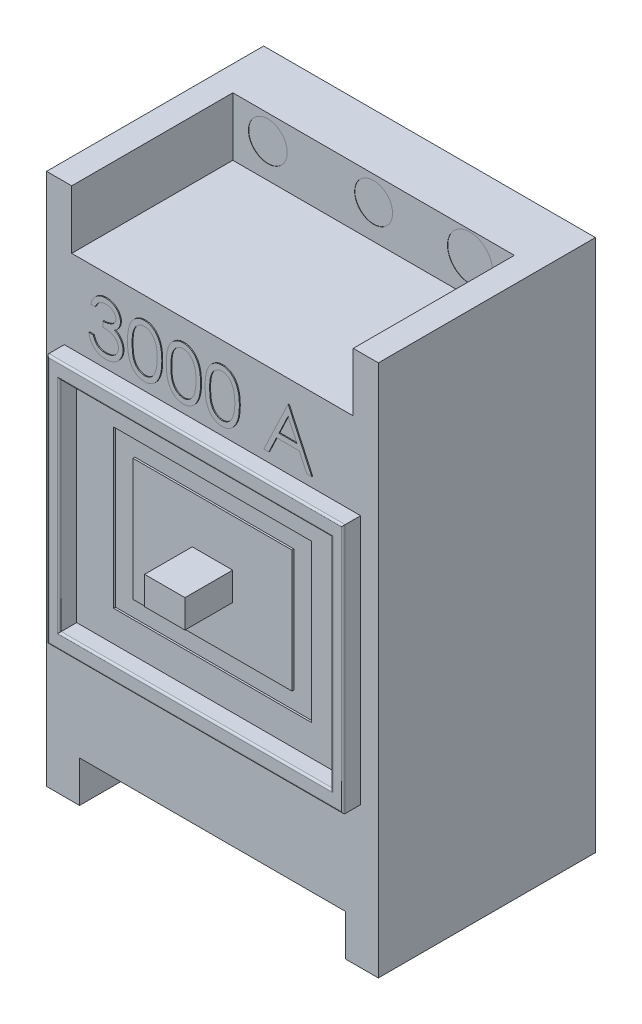
from build123d import *

# Parameters (mm, degrees)
CROQUIS1_W              = 350
CROQUIS1_H              = 562
SALIENTE_EXTRUIR1_DEPTH = 229
CROQUIS2_W              = 208.674633314
CROQUIS2_H              = 165.712208808
CROQUIS2_W_2            = 167.758038546
CROQUIS2_H_2            = 128.887273516
CORTAR_EXTRUIR1_DEPTH   = 2
CROQUIS3_W              = 296.993565644
CROQUIS3_H              = 123.360485072
CROQUIS3_W_2            = 280.429302812
CROQUIS3_H_2            = 86.946646854
CORTAR_EXTRUIR2_DEPTH   = 170
CROQUIS4_R              = 20.028661691
CROQUIS4_R_2            = 20.45866054
CROQUIS4_R_3            = 23.776281168
CORTAR_EXTRUIR4_DEPTH   = 0.3
CROQUIS5_W              = 312.557321138
CROQUIS5_H              = 264.016222022
CROQUIS5_W_2            = 286.51087771
CROQUIS5_H_2            = 230.866203114
SALIENTE_EXTRUIR2_DEPTH = 18.3
REDONDEO2_R             = 2
CROQUIS6_W              = 42.621452882
CROQUIS6_H              = 29.598231168
SALIENTE_EXTRUIR3_DEPTH = 50.3
SALIENTE_EXTRUIR4_DEPTH = 1


with BuildPart() as part:
    # Croquis1 → Saliente-Extruir1 (new body)
    with BuildSketch(Plane.XY):
        Rectangle(CROQUIS1_W, CROQUIS1_H)
    extrude(amount=SALIENTE_EXTRUIR1_DEPTH)

    # Croquis2 → Cortar-Extruir1 (cut)
    with BuildSketch(Plane.XY.offset(229)):
        Rectangle(CROQUIS2_W, CROQUIS2_H)
        Rectangle(CROQUIS2_W_2, CROQUIS2_H_2, mode=Mode.SUBTRACT)
    extrude(amount=-CORTAR_EXTRUIR1_DEPTH, mode=Mode.SUBTRACT)

    # Croquis3 → Cortar-Extruir2 (cut)
    with BuildSketch(Plane.XY.offset(229)):
        with Locations((0, 281)):
            Rectangle(CROQUIS3_W, CROQUIS3_H)
        with Locations((0, -281)):
            Rectangle(CROQUIS3_W_2, CROQUIS3_H_2)
    extrude(amount=-CORTAR_EXTRUIR2_DEPTH, mode=Mode.SUBTRACT)

    # Croquis4 → Cortar-Extruir4 (cut)
    with BuildSketch(Plane.XY.offset(59)):
        with Locations((0, 255.134947076)):
            Circle(CROQUIS4_R)
        with Locations((-111.577875374, 255.134947076)):
            Circle(CROQUIS4_R_2)
        with Locations((101.715058762, 255.134947076)):
            Circle(CROQUIS4_R_3)
        with Locations((101.715058762, -255.134947076)):
            Circle(CROQUIS4_R_3)
        with Locations((-111.577875374, -255.134947076)):
            Circle(CROQUIS4_R_2)
        with Locations((0, -255.134947076)):
            Circle(CROQUIS4_R)
    extrude(amount=-CORTAR_EXTRUIR4_DEPTH, mode=Mode.SUBTRACT)

    # Croquis5 → Saliente-Extruir2 (add)
    with BuildSketch(Plane.XY.offset(229)):
        Rectangle(CROQUIS5_W, CROQUIS5_H)
        Rectangle(CROQUIS5_W_2, CROQUIS5_H_2, mode=Mode.SUBTRACT)
    extrude(amount=SALIENTE_EXTRUIR2_DEPTH)

    # Redondeo2
    redondeo2_edges = [part.edges().sort_by_distance(p)[0] for p in [
        (156.278660569, 0, 247.3),
        (0, 132.008111011, 247.3),
        (-156.278660569, 0, 247.3),
        (0, -132.008111011, 247.3),
        (143.255438855, 0, 247.3),
        (0, 115.433101557, 247.3),
        (-143.255438855, 0, 247.3),
        (0, -115.433101557, 247.3),
    ]]
    fillet(redondeo2_edges, radius=REDONDEO2_R)

    # Croquis6 → Saliente-Extruir3 (add)
    with BuildSketch(Plane.XY.offset(229)):
        Rectangle(CROQUIS6_W, CROQUIS6_H)
    extrude(amount=SALIENTE_EXTRUIR3_DEPTH)

    # Croquis7 → Saliente-Extruir4 (add)
    with BuildSketch(Plane.XY.offset(229)):
        with BuildLine():
            Line((-122.688926728, 183.752225493), (-127.46160301, 183.752225493))
            add(Edge.make_bspline(
                [(-127.46160301, 183.752225493), (-127.332303426, 184.287570504), (-127.079533316, 185.334126213), (-126.55231608, 186.829389396), (-125.977969897, 188.244368045), (-125.288298663, 189.552567136), (-124.536030824, 190.780277606), (-123.674149329, 191.899653642), (-122.742418044, 192.939164219), (-121.711842163, 193.861680181), (-120.631067552, 194.697047141), (-119.484865446, 195.409296896), (-118.296296514, 196.022007998), (-117.057125785, 196.526777557), (-115.763664008, 196.907031451), (-114.427604785, 197.182917627), (-113.045446888, 197.362079397), (-112.107214301, 197.379564831), (-111.630806235, 197.388443442)],
                knots=[0, 0, 0, 0, 0.001651123, 0.003227811, 0.004751232, 0.006228357, 0.007659115, 0.00906539, 0.010460646, 0.011840855, 0.013208797, 0.014553731, 0.015883047, 0.017216413, 0.018561304, 0.019921468, 0.021306273, 0.022734808, 0.022734808, 0.022734808, 0.022734808], degree=3))
            add(Edge.make_bspline(
                [(-111.630806235, 197.388443442), (-110.936673284, 197.367486531), (-109.563548438, 197.32602984), (-107.546261355, 196.947463875), (-105.600939562, 196.34841307), (-103.748875974, 195.520704241), (-102.028562325, 194.499817013), (-100.497911945, 193.284781394), (-99.177672055, 191.89904058), (-98.07006802, 190.368445241), (-97.202833793, 188.732658224), (-96.563346379, 187.049089408), (-96.174034087, 185.321732453), (-96.123579412, 184.155433009), (-96.098301728, 183.571119473)],
                knots=[0, 0, 0, 0, 0.002080695, 0.004116004, 0.006134431, 0.008175559, 0.010187115, 0.012120416, 0.014019275, 0.015911607, 0.017770294, 0.019557065, 0.021301898, 0.023053709, 0.023053709, 0.023053709, 0.023053709], degree=3))
            add(Edge.make_bspline(
                [(-96.098301728, 183.571119473), (-96.115982078, 183.008814444), (-96.15057978, 181.908470762), (-96.444348531, 180.302070371), (-96.938725426, 178.788051841), (-97.623544372, 177.360041647), (-98.510023391, 176.027094037), (-99.58386978, 174.786209991), (-100.852662904, 173.631885765), (-101.814163767, 172.970622916), (-102.309172872, 172.630185229)],
                knots=[0, 0, 0, 0, 0.001685949, 0.003299141, 0.004879172, 0.006451571, 0.008035297, 0.009666887, 0.01136384, 0.013164531, 0.013164531, 0.013164531, 0.013164531], degree=3))
            add(Edge.make_bspline(
                [(-102.309172872, 172.630185229), (-101.743449658, 172.357013333), (-100.622588349, 171.815780798), (-99.094758963, 170.754347511), (-97.707824247, 169.528803119), (-96.934360416, 168.572411988), (-96.545740129, 168.091881442)],
                knots=[0, 0, 0, 0, 0.001882049, 0.003728883, 0.005562024, 0.007413154, 0.007413154, 0.007413154, 0.007413154], degree=3))
            add(Edge.make_bspline(
                [(-96.545740129, 168.091881442), (-96.289841947, 167.741527142), (-95.782236092, 167.046555834), (-95.155676884, 165.929196106), (-94.587258752, 164.799451781), (-94.14433158, 163.627042163), (-93.801329736, 162.42555596), (-93.556148489, 161.192930124), (-93.403835248, 159.928158101), (-93.382022548, 159.072510076), (-93.371058138, 158.642408536)],
                knots=[0, 0, 0, 0, 0.0013004, 0.002579506, 0.003837317, 0.005091694, 0.006332609, 0.007582, 0.008858485, 0.010148634, 0.010148634, 0.010148634, 0.010148634], degree=3))
            add(Edge.make_bspline(
                [(-93.371058138, 158.642408536), (-93.39832513, 157.897723326), (-93.452730795, 156.411857406), (-93.939021274, 154.216615609), (-94.692876748, 152.07074454), (-95.763444726, 150.018330599), (-97.068170856, 148.098025845), (-98.620414912, 146.379871714), (-100.40254, 144.902973635), (-102.390085118, 143.669013223), (-104.543426272, 142.68260858), (-106.846563258, 141.997976828), (-109.266310953, 141.552074844), (-110.925676837, 141.504259295), (-111.769299073, 141.479949852)],
                knots=[0, 0, 0, 0, 0.002231528, 0.004452555, 0.00671349, 0.009038643, 0.011375992, 0.013661291, 0.015961021, 0.018296305, 0.020660953, 0.023043603, 0.025488667, 0.028017294, 0.028017294, 0.028017294, 0.028017294], degree=3))
            add(Edge.make_bspline(
                [(-111.769299073, 141.479949852), (-112.337871977, 141.493142042), (-113.456633855, 141.519099874), (-115.101355154, 141.696552048), (-116.671291476, 142.02065386), (-118.168565472, 142.456790334), (-119.594507284, 143.009749858), (-120.944765625, 143.698351289), (-122.227647704, 144.508400523), (-123.431047481, 145.44945927), (-124.554821504, 146.502164484), (-125.569105308, 147.685204334), (-126.490809198, 148.976709531), (-127.295253685, 150.391681111), (-128.019080166, 151.911833065), (-128.61442081, 153.556630338), (-129.138416709, 155.311368808), (-129.382039472, 156.534199328), (-129.507035702, 157.161600493)],
                knots=[0, 0, 0, 0, 0.001705725, 0.003356299, 0.004954612, 0.006508716, 0.00803005, 0.009535598, 0.011048816, 0.01257462, 0.01411202, 0.015660417, 0.017241884, 0.018864546, 0.020537249, 0.022286629, 0.024107065, 0.02602525, 0.02602525, 0.02602525, 0.02602525], degree=3))
            Line((-129.507035702, 157.161600493), (-124.73435942, 157.161600493))
            add(Edge.make_bspline(
                [(-124.73435942, 157.161600493), (-124.610017229, 156.752119861), (-124.368160868, 155.955644464), (-123.956472685, 154.809355962), (-123.487440316, 153.758524043), (-122.984276424, 152.795440141), (-122.455830357, 151.910619583), (-121.864531968, 151.127459291), (-121.254176154, 150.41156062), (-120.794092194, 150.008224722), (-120.568920969, 149.810826755)],
                knots=[0, 0, 0, 0, 0.001283755, 0.002497015, 0.003651166, 0.00473283, 0.00575599, 0.006738233, 0.007674269, 0.008571489, 0.008571489, 0.008571489, 0.008571489], degree=3))
            add(Edge.make_bspline(
                [(-120.568920969, 149.810826755), (-120.271157987, 149.581261017), (-119.67655115, 149.122838159), (-118.707615653, 148.537819664), (-117.688588661, 148.030910799), (-116.597390334, 147.643695144), (-115.457567688, 147.315830295), (-114.25069724, 147.101274049), (-112.987426529, 146.954065746), (-112.124860637, 146.941075367), (-111.684072711, 146.934437031)],
                knots=[0, 0, 0, 0, 0.001127137, 0.002250794, 0.003389502, 0.004535412, 0.005719271, 0.006943705, 0.008208399, 0.009530095, 0.009530095, 0.009530095, 0.009530095], degree=3))
            add(Edge.make_bspline(
                [(-111.684072711, 146.934437031), (-111.186394936, 146.943795492), (-110.21322901, 146.962095153), (-108.793215799, 147.130386563), (-107.442298886, 147.375482434), (-106.175477055, 147.754026311), (-104.976156185, 148.221730355), (-103.861148227, 148.808979073), (-102.815815964, 149.497975924), (-101.853548266, 150.281095032), (-100.988281617, 151.1383995), (-100.22642962, 152.035082039), (-99.578763112, 152.967361956), (-99.056316921, 153.940398332), (-98.643774006, 154.950161801), (-98.362928375, 155.999486049), (-98.167654192, 157.079783617), (-98.151751294, 157.81412504), (-98.14373442, 158.184316839)],
                knots=[0, 0, 0, 0, 0.001492412, 0.002918283, 0.004284732, 0.00560617, 0.006878202, 0.008140966, 0.009378996, 0.010628524, 0.011856429, 0.013028146, 0.014154023, 0.015255081, 0.016335223, 0.017418145, 0.018509262, 0.019618485, 0.019618485, 0.019618485, 0.019618485], degree=3))
            add(Edge.make_bspline(
                [(-98.14373442, 158.184316839), (-98.166986805, 158.679834486), (-98.213375875, 159.668404154), (-98.567541415, 161.12279851), (-99.150086764, 162.524100325), (-99.965621405, 163.848401428), (-100.958374467, 165.075762403), (-102.118711954, 166.17086284), (-103.456269445, 167.074489634), (-104.68733742, 167.698817094), (-105.777783342, 168.124830438), (-106.710968175, 168.408589853), (-107.755700207, 168.648872703), (-108.899345498, 168.872420415), (-110.150521263, 169.062677828), (-111.507865364, 169.221337489), (-112.971652856, 169.348289352), (-113.985001303, 169.404982013), (-114.507195958, 169.434196647)],
                knots=[0, 0, 0, 0, 0.001485438, 0.002963484, 0.004463141, 0.00602162, 0.007612211, 0.009187495, 0.010789071, 0.012437546, 0.013317911, 0.014298535, 0.015360557, 0.016532661, 0.017793761, 0.019156134, 0.020631837, 0.022200803, 0.022200803, 0.022200803, 0.022200803], degree=3))
            Line((-114.507195958, 169.434196647), (-114.507195958, 174.888683826))
            add(Edge.make_bspline(
                [(-114.507195958, 174.888683826), (-113.84925021, 174.899848906), (-112.560496116, 174.921718556), (-110.677966403, 175.186227056), (-108.877806737, 175.552123599), (-107.19991183, 176.112580923), (-105.670590577, 176.763523933), (-104.343800409, 177.521010453), (-103.238129594, 178.363017776), (-102.358951278, 179.302542192), (-101.697540194, 180.310175655), (-101.213943374, 181.360378584), (-100.928279131, 182.462355788), (-100.890145639, 183.214409591), (-100.87097801, 183.592426064)],
                knots=[0, 0, 0, 0, 0.00197227, 0.003863192, 0.005693576, 0.007475736, 0.009159968, 0.01067296, 0.012047401, 0.013313755, 0.014513374, 0.015648088, 0.01676947, 0.017902783, 0.017902783, 0.017902783, 0.017902783], degree=3))
            add(Edge.make_bspline(
                [(-100.87097801, 183.592426064), (-100.877274836, 183.870149874), (-100.889802074, 184.422668221), (-101.047784997, 185.229884667), (-101.285186719, 186.012423147), (-101.611563535, 186.766955839), (-102.048412536, 187.488249697), (-102.571199214, 188.182454167), (-103.193694866, 188.845605802), (-103.907014167, 189.463728728), (-104.673003539, 190.052813441), (-105.512504139, 190.5529244), (-106.40020366, 190.980578567), (-107.3370849, 191.333238662), (-108.326188235, 191.598526311), (-109.362866412, 191.789003944), (-110.449096231, 191.908094308), (-111.190165281, 191.925240185), (-111.566886463, 191.933956262)],
                knots=[0, 0, 0, 0, 0.000832049, 0.001655322, 0.002457367, 0.003282705, 0.004114004, 0.004981185, 0.005885649, 0.00683672, 0.007810434, 0.008780586, 0.009762135, 0.010763375, 0.01177902, 0.012830031, 0.013922968, 0.015053021, 0.015053021, 0.015053021, 0.015053021], degree=3))
            add(Edge.make_bspline(
                [(-111.566886463, 191.933956262), (-112.172418326, 191.912815013), (-113.355162889, 191.871521238), (-115.060228475, 191.509842949), (-116.645323498, 190.932779534), (-117.856924059, 190.243960494), (-118.751623744, 189.563993634), (-119.390967792, 188.970150731), (-120.01881819, 188.310204488), (-120.593869734, 187.543507496), (-121.17542914, 186.721981929), (-121.704879808, 185.803865668), (-122.219365739, 184.813108183), (-122.529375194, 184.112701479), (-122.688926728, 183.752225493)],
                knots=[0, 0, 0, 0, 0.001814848, 0.003544819, 0.005203179, 0.006858867, 0.007702632, 0.008569747, 0.009474211, 0.010430993, 0.011441654, 0.012492233, 0.01360717, 0.014789494, 0.014789494, 0.014789494, 0.014789494], degree=3))
        make_face()
        with BuildLine():
            add(Edge.make_bspline(
                [(-88.598381856, 169.412890056), (-88.593397737, 170.265269828), (-88.583716015, 171.921029821), (-88.47600999, 174.333705748), (-88.297087869, 176.597104139), (-88.051886252, 178.711333334), (-87.753494156, 180.676939145), (-87.3551592, 182.488668696), (-86.902164311, 184.154907254), (-86.377152238, 185.681088309), (-85.784746708, 187.087773443), (-85.139973271, 188.40097351), (-84.417243207, 189.61870155), (-83.657861864, 190.760393441), (-82.831089869, 191.807360474), (-81.960455211, 192.774388002), (-81.011977095, 193.63912653), (-80.01789785, 194.426912578), (-78.969217322, 195.117501068), (-77.895827239, 195.725784234), (-76.79033939, 196.245439003), (-75.64973555, 196.654029572), (-74.484267577, 196.991515456), (-73.289861272, 197.222306091), (-72.064544548, 197.367519902), (-71.237478336, 197.381402757), (-70.818032046, 197.388443442)],
                knots=[0, 0, 0, 0, 0.002556991, 0.004966991, 0.007243359, 0.009366895, 0.011351298, 0.013204757, 0.01492865, 0.016528951, 0.018042544, 0.019505191, 0.020913886, 0.02228783, 0.023615566, 0.024912646, 0.026186817, 0.0274613, 0.028714094, 0.0299496, 0.031160192, 0.032373452, 0.03358071, 0.03479668, 0.036019027, 0.037276838, 0.037276838, 0.037276838, 0.037276838], degree=3))
            add(Edge.make_bspline(
                [(-70.818032046, 197.388443442), (-70.395081892, 197.381031264), (-69.553967107, 197.366290776), (-68.310431834, 197.224616799), (-67.095624973, 196.989538609), (-65.914725612, 196.656457229), (-64.75803363, 196.243228635), (-63.634596322, 195.725287064), (-62.537435505, 195.122380846), (-61.483986547, 194.413947682), (-60.462684472, 193.62409556), (-59.498615334, 192.731217794), (-58.591691381, 191.744330006), (-57.730530357, 190.673991042), (-56.939564149, 189.49967178), (-56.186313551, 188.241796797), (-55.512096312, 186.878368353), (-54.862758185, 185.432135137), (-54.302273596, 183.863080722), (-53.79680488, 182.180049745), (-53.388388552, 180.36316268), (-53.048191555, 178.42195216), (-52.784642055, 176.349289169), (-52.592693571, 174.149616708), (-52.491298427, 171.821487593), (-52.472203301, 170.229729489), (-52.462404292, 169.412890056)],
                knots=[0, 0, 0, 0, 0.001268458, 0.002522564, 0.003748989, 0.004976756, 0.00620003, 0.007429967, 0.008684073, 0.009951636, 0.011234507, 0.012553839, 0.013888226, 0.015252513, 0.016670842, 0.018132481, 0.019647535, 0.021231118, 0.022885812, 0.024641926, 0.026500033, 0.028468674, 0.030552503, 0.032766057, 0.035090918, 0.037541546, 0.037541546, 0.037541546, 0.037541546], degree=3))
            add(Edge.make_bspline(
                [(-52.462404292, 169.412890056), (-52.472304886, 168.599613391), (-52.491595791, 167.014976974), (-52.591556891, 164.69732328), (-52.788458663, 162.50932444), (-53.034763646, 160.445732966), (-53.37589801, 158.515137826), (-53.795348653, 156.71085834), (-54.261069361, 155.025102794), (-54.835955545, 153.471681344), (-55.4651765, 152.028923827), (-56.149774114, 150.681658175), (-56.883216883, 149.417976059), (-57.682284081, 148.247992405), (-58.533995676, 147.163419203), (-59.456580791, 146.183400862), (-60.424032593, 145.284323634), (-61.448340175, 144.484300958), (-62.518218549, 143.784058811), (-63.611611023, 143.157829073), (-64.747917825, 142.652870141), (-65.90138803, 142.219290384), (-67.08852065, 141.888040304), (-68.307835897, 141.658998453), (-69.553131632, 141.498362991), (-70.394938627, 141.486108817), (-70.818032046, 141.479949852)],
                knots=[0, 0, 0, 0, 0.002439977, 0.004754195, 0.006957136, 0.009029058, 0.010987208, 0.012834933, 0.014585091, 0.016229775, 0.01779932, 0.019304869, 0.020761101, 0.02217943, 0.023552053, 0.024893691, 0.026213023, 0.027510847, 0.028787287, 0.030046586, 0.03128622, 0.032513154, 0.03374092, 0.034977804, 0.036233131, 0.037501589, 0.037501589, 0.037501589, 0.037501589], degree=3))
            add(Edge.make_bspline(
                [(-70.818032046, 141.479949852), (-71.2374667, 141.487035957), (-72.064509967, 141.501008372), (-73.289994767, 141.645566124), (-74.479468537, 141.877975833), (-75.638800855, 142.203393483), (-76.773939671, 142.601718558), (-77.869416998, 143.120671583), (-78.937413249, 143.718338713), (-79.975079053, 144.398989143), (-80.962915621, 145.178803789), (-81.906481751, 146.041316883), (-82.782073336, 147.008051895), (-83.597024264, 148.063744123), (-84.371557329, 149.198681264), (-85.08402461, 150.428358989), (-85.743029248, 151.747901441), (-86.345397931, 153.165833766), (-86.87946932, 154.702846768), (-87.351228156, 156.376524196), (-87.723712024, 158.201638388), (-88.042540536, 160.163530668), (-88.299700492, 162.270631514), (-88.475264339, 164.524084847), (-88.58377407, 166.922486423), (-88.593423738, 168.567606976), (-88.598381856, 169.412890056)],
                knots=[0, 0, 0, 0, 0.001257811, 0.002480158, 0.003696128, 0.004890247, 0.006089867, 0.007300458, 0.008521458, 0.009759488, 0.011019012, 0.012293184, 0.013590264, 0.014926392, 0.016291511, 0.017709401, 0.019186333, 0.020713883, 0.022327743, 0.024064753, 0.0259264, 0.027912489, 0.030026705, 0.032292454, 0.034691811, 0.037227497, 0.037227497, 0.037227497, 0.037227497], degree=3))
        make_face()
        with BuildLine():
            add(Edge.make_bspline(
                [(-83.825705574, 169.434196647), (-83.823890618, 168.723866864), (-83.820368146, 167.345256237), (-83.728346341, 165.341944974), (-83.602987012, 163.473454745), (-83.441296302, 161.737413063), (-83.201176143, 160.139696177), (-82.932127826, 158.669315403), (-82.6047123, 157.33405217), (-82.217324609, 156.124743811), (-81.776085903, 155.020867161), (-81.294326628, 153.99369084), (-80.776786108, 153.031080792), (-80.197579229, 152.141683518), (-79.56677267, 151.322598607), (-78.898614702, 150.55932866), (-78.168168954, 149.878654527), (-77.157668337, 149.062294153), (-75.823632264, 148.218700745), (-74.142793954, 147.484099176), (-72.415642437, 147.022448602), (-71.243356746, 146.96374021), (-70.658232617, 146.934437031)],
                knots=[0, 0, 0, 0, 0.002130766, 0.004135398, 0.006014731, 0.007748962, 0.009364052, 0.010860072, 0.012232074, 0.013485365, 0.014666392, 0.015795893, 0.016887583, 0.017942474, 0.018975899, 0.01998712, 0.020981935, 0.02196689, 0.023882114, 0.025695053, 0.027454654, 0.029208149, 0.029208149, 0.029208149, 0.029208149], degree=3))
            add(Edge.make_bspline(
                [(-70.658232617, 146.934437031), (-70.069323638, 146.95871474), (-68.892721558, 147.007220033), (-67.173693946, 147.475195848), (-65.504862217, 148.181283904), (-64.197029824, 149.016191625), (-63.202045963, 149.811301902), (-62.489159054, 150.489205549), (-61.834846607, 151.248267112), (-61.214265866, 152.067247664), (-60.64508859, 152.961794035), (-60.127511378, 153.927604665), (-59.655211013, 154.967361584), (-59.386128384, 155.69320571), (-59.24855338, 156.06431108)],
                knots=[0, 0, 0, 0, 0.001763241, 0.003522842, 0.005307769, 0.007184595, 0.008154571, 0.009126593, 0.010130776, 0.011157756, 0.012206875, 0.013307933, 0.014442647, 0.015629713, 0.015629713, 0.015629713, 0.015629713], degree=3))
            add(Edge.make_bspline(
                [(-59.24855338, 156.06431108), (-59.088223037, 156.538835818), (-58.762683682, 157.502324539), (-58.343132633, 158.996925102), (-58.012719058, 160.565054242), (-57.715460703, 162.197340525), (-57.512565787, 163.905821625), (-57.349256603, 165.685211304), (-57.253064076, 167.536851182), (-57.241140064, 168.794891503), (-57.235080574, 169.434196647)],
                knots=[0, 0, 0, 0, 0.00150253, 0.003050781, 0.004653491, 0.00630863, 0.008026423, 0.009812685, 0.011668836, 0.013586696, 0.013586696, 0.013586696, 0.013586696], degree=3))
            add(Edge.make_bspline(
                [(-57.235080574, 169.434196647), (-57.243440503, 170.073398387), (-57.259794311, 171.323813635), (-57.322304885, 173.155044348), (-57.483726305, 174.894341094), (-57.663009702, 176.54919683), (-57.927354263, 178.110450983), (-58.21237244, 179.591173567), (-58.59529586, 180.97302035), (-59.004332226, 182.27762603), (-59.472485183, 183.490168475), (-59.987822652, 184.616300989), (-60.53819934, 185.661460316), (-61.135990633, 186.622778898), (-61.774100039, 187.504562662), (-62.469369657, 188.289131885), (-63.194220565, 189.000802888), (-64.20948384, 189.813147532), (-65.538624433, 190.641433276), (-67.192495171, 191.403684081), (-68.913602156, 191.841415799), (-70.077108443, 191.903131683), (-70.658232617, 191.933956262)],
                knots=[0, 0, 0, 0, 0.001917859, 0.003751743, 0.005494624, 0.007156981, 0.00874375, 0.010243861, 0.011678105, 0.013042601, 0.014344397, 0.015574333, 0.016756225, 0.017885474, 0.018967925, 0.020017207, 0.021026743, 0.022011698, 0.023912229, 0.025709987, 0.02745664, 0.02919952, 0.02919952, 0.02919952, 0.02919952], degree=3))
            add(Edge.make_bspline(
                [(-70.658232617, 191.933956262), (-71.246426239, 191.903089156), (-72.42388503, 191.841298711), (-74.162880828, 191.40531497), (-75.829799271, 190.645385814), (-77.155425113, 189.810404141), (-78.171396469, 189.015142191), (-78.886801179, 188.325511231), (-79.5575865, 187.571154126), (-80.175517679, 186.744536459), (-80.754270734, 185.856176084), (-81.285794727, 184.899084299), (-81.764689295, 183.868410946), (-82.206618435, 182.765030144), (-82.595187816, 181.555826115), (-82.915703054, 180.222207603), (-83.211801866, 178.756503608), (-83.42141605, 177.150133442), (-83.607759439, 175.413656937), (-83.727513706, 173.540502114), (-83.820675974, 171.533831019), (-83.823995462, 170.148092377), (-83.825705574, 169.434196647)],
                knots=[0, 0, 0, 0, 0.00176411, 0.003531433, 0.005338918, 0.007239449, 0.008217756, 0.00920484, 0.010216062, 0.011243041, 0.012297933, 0.013394757, 0.014524257, 0.015705284, 0.016958576, 0.018330578, 0.019818153, 0.021442283, 0.023188189, 0.025056893, 0.027072169, 0.029213587, 0.029213587, 0.029213587, 0.029213587], degree=3))
        make_face(mode=Mode.SUBTRACT)
        with BuildLine():
            add(Edge.make_bspline(
                [(-47.68972801, 169.412890056), (-47.684743891, 170.265269828), (-47.675062169, 171.921029821), (-47.567356144, 174.333705748), (-47.388434023, 176.597104139), (-47.143232406, 178.711333334), (-46.84484031, 180.676939145), (-46.446505354, 182.488668696), (-45.993510465, 184.154907254), (-45.468498391, 185.681088309), (-44.876092861, 187.087773443), (-44.231319425, 188.40097351), (-43.508589361, 189.61870155), (-42.749208018, 190.760393441), (-41.922436023, 191.807360474), (-41.051801365, 192.774388002), (-40.103323249, 193.63912653), (-39.109244004, 194.426912578), (-38.060563476, 195.117501068), (-36.987173393, 195.725784234), (-35.881685544, 196.245439003), (-34.741081704, 196.654029572), (-33.575613731, 196.991515456), (-32.381207426, 197.222306091), (-31.155890702, 197.367519902), (-30.32882449, 197.381402757), (-29.9093782, 197.388443442)],
                knots=[0, 0, 0, 0, 0.002556991, 0.004966991, 0.007243359, 0.009366895, 0.011351298, 0.013204757, 0.01492865, 0.016528951, 0.018042544, 0.019505191, 0.020913886, 0.02228783, 0.023615566, 0.024912646, 0.026186817, 0.0274613, 0.028714094, 0.0299496, 0.031160192, 0.032373452, 0.03358071, 0.03479668, 0.036019027, 0.037276838, 0.037276838, 0.037276838, 0.037276838], degree=3))
            add(Edge.make_bspline(
                [(-29.9093782, 197.388443442), (-29.486428046, 197.381031264), (-28.645313261, 197.366290776), (-27.401777987, 197.224616799), (-26.186971127, 196.989538609), (-25.006071766, 196.656457229), (-23.849379784, 196.243228635), (-22.725942476, 195.725287064), (-21.628781659, 195.122380846), (-20.575332701, 194.413947682), (-19.554030626, 193.62409556), (-18.589961488, 192.731217794), (-17.683037535, 191.744330006), (-16.821876511, 190.673991042), (-16.030910303, 189.49967178), (-15.277659704, 188.241796797), (-14.603442466, 186.878368353), (-13.954104339, 185.432135137), (-13.39361975, 183.863080722), (-12.888151033, 182.180049745), (-12.479734706, 180.36316268), (-12.139537709, 178.42195216), (-11.875988209, 176.349289169), (-11.684039725, 174.149616708), (-11.582644581, 171.821487593), (-11.563549455, 170.229729489), (-11.553750446, 169.412890056)],
                knots=[0, 0, 0, 0, 0.001268458, 0.002522564, 0.003748989, 0.004976756, 0.00620003, 0.007429967, 0.008684073, 0.009951636, 0.011234507, 0.012553839, 0.013888226, 0.015252513, 0.016670842, 0.018132481, 0.019647535, 0.021231118, 0.022885812, 0.024641926, 0.026500033, 0.028468674, 0.030552503, 0.032766057, 0.035090918, 0.037541546, 0.037541546, 0.037541546, 0.037541546], degree=3))
            add(Edge.make_bspline(
                [(-11.553750446, 169.412890056), (-11.56365104, 168.599613391), (-11.582941945, 167.014976974), (-11.682903044, 164.69732328), (-11.879804817, 162.50932444), (-12.1261098, 160.445732966), (-12.467244164, 158.515137826), (-12.886694807, 156.71085834), (-13.352415515, 155.025102794), (-13.927301699, 153.471681344), (-14.556522654, 152.028923827), (-15.241120268, 150.681658175), (-15.974563036, 149.417976059), (-16.773630235, 148.247992405), (-17.625341829, 147.163419203), (-18.547926945, 146.183400862), (-19.515378746, 145.284323634), (-20.539686329, 144.484300958), (-21.609564703, 143.784058811), (-22.702957177, 143.157829073), (-23.839263979, 142.652870141), (-24.992734184, 142.219290384), (-26.179866804, 141.888040304), (-27.399182051, 141.658998453), (-28.644477786, 141.498362991), (-29.486284781, 141.486108817), (-29.9093782, 141.479949852)],
                knots=[0, 0, 0, 0, 0.002439977, 0.004754195, 0.006957136, 0.009029058, 0.010987208, 0.012834933, 0.014585091, 0.016229775, 0.01779932, 0.019304869, 0.020761101, 0.02217943, 0.023552053, 0.024893691, 0.026213023, 0.027510847, 0.028787287, 0.030046586, 0.03128622, 0.032513154, 0.03374092, 0.034977804, 0.036233131, 0.037501589, 0.037501589, 0.037501589, 0.037501589], degree=3))
            add(Edge.make_bspline(
                [(-29.9093782, 141.479949852), (-30.328812853, 141.487035957), (-31.155856121, 141.501008372), (-32.381340921, 141.645566124), (-33.570814691, 141.877975833), (-34.730147009, 142.203393483), (-35.865285825, 142.601718558), (-36.960763152, 143.120671583), (-38.028759403, 143.718338713), (-39.066425207, 144.398989143), (-40.054261775, 145.178803789), (-40.997827905, 146.041316883), (-41.87341949, 147.008051895), (-42.688370418, 148.063744123), (-43.462903483, 149.198681264), (-44.175370764, 150.428358989), (-44.834375402, 151.747901441), (-45.436744084, 153.165833766), (-45.970815473, 154.702846768), (-46.44257431, 156.376524196), (-46.815058177, 158.201638388), (-47.13388669, 160.163530668), (-47.391046646, 162.270631514), (-47.566610492, 164.524084847), (-47.675120224, 166.922486423), (-47.684769892, 168.567606976), (-47.68972801, 169.412890056)],
                knots=[0, 0, 0, 0, 0.001257811, 0.002480158, 0.003696128, 0.004890247, 0.006089867, 0.007300458, 0.008521458, 0.009759488, 0.011019012, 0.012293184, 0.013590264, 0.014926392, 0.016291511, 0.017709401, 0.019186333, 0.020713883, 0.022327743, 0.024064753, 0.0259264, 0.027912489, 0.030026705, 0.032292454, 0.034691811, 0.037227497, 0.037227497, 0.037227497, 0.037227497], degree=3))
        make_face()
        with BuildLine():
            add(Edge.make_bspline(
                [(-42.917051728, 169.434196647), (-42.915236772, 168.723866864), (-42.9117143, 167.345256237), (-42.819692495, 165.341944974), (-42.694333166, 163.473454745), (-42.532642456, 161.737413063), (-42.292522297, 160.139696177), (-42.02347398, 158.669315403), (-41.696058454, 157.33405217), (-41.308670763, 156.124743811), (-40.867432057, 155.020867161), (-40.385672782, 153.99369084), (-39.868132262, 153.031080792), (-39.288925383, 152.141683518), (-38.658118824, 151.322598607), (-37.989960856, 150.55932866), (-37.259515108, 149.878654527), (-36.249014491, 149.062294153), (-34.914978418, 148.218700745), (-33.234140108, 147.484099176), (-31.506988591, 147.022448602), (-30.3347029, 146.96374021), (-29.749578771, 146.934437031)],
                knots=[0, 0, 0, 0, 0.002130766, 0.004135398, 0.006014731, 0.007748962, 0.009364052, 0.010860072, 0.012232074, 0.013485365, 0.014666392, 0.015795893, 0.016887583, 0.017942474, 0.018975899, 0.01998712, 0.020981935, 0.02196689, 0.023882114, 0.025695053, 0.027454654, 0.029208149, 0.029208149, 0.029208149, 0.029208149], degree=3))
            add(Edge.make_bspline(
                [(-29.749578771, 146.934437031), (-29.160669792, 146.95871474), (-27.984067712, 147.007220033), (-26.2650401, 147.475195848), (-24.596208371, 148.181283904), (-23.288375978, 149.016191625), (-22.293392116, 149.811301902), (-21.580505208, 150.489205549), (-20.926192761, 151.248267112), (-20.30561202, 152.067247664), (-19.736434744, 152.961794035), (-19.218857532, 153.927604665), (-18.746557167, 154.967361584), (-18.477474538, 155.69320571), (-18.339899534, 156.06431108)],
                knots=[0, 0, 0, 0, 0.001763241, 0.003522842, 0.005307769, 0.007184595, 0.008154571, 0.009126593, 0.010130776, 0.011157756, 0.012206875, 0.013307933, 0.014442647, 0.015629713, 0.015629713, 0.015629713, 0.015629713], degree=3))
            add(Edge.make_bspline(
                [(-18.339899534, 156.06431108), (-18.179569191, 156.538835818), (-17.854029836, 157.502324539), (-17.434478787, 158.996925102), (-17.104065212, 160.565054242), (-16.806806857, 162.197340525), (-16.603911941, 163.905821625), (-16.440602757, 165.685211304), (-16.34441023, 167.536851182), (-16.332486217, 168.794891503), (-16.326426728, 169.434196647)],
                knots=[0, 0, 0, 0, 0.00150253, 0.003050781, 0.004653491, 0.00630863, 0.008026423, 0.009812685, 0.011668836, 0.013586696, 0.013586696, 0.013586696, 0.013586696], degree=3))
            add(Edge.make_bspline(
                [(-16.326426728, 169.434196647), (-16.334786657, 170.073398387), (-16.351140465, 171.323813635), (-16.413651039, 173.155044348), (-16.575072459, 174.894341094), (-16.754355856, 176.54919683), (-17.018700417, 178.110450983), (-17.303718593, 179.591173567), (-17.686642014, 180.97302035), (-18.09567838, 182.27762603), (-18.563831337, 183.490168475), (-19.079168806, 184.616300989), (-19.629545494, 185.661460316), (-20.227336787, 186.622778898), (-20.865446193, 187.504562662), (-21.560715811, 188.289131885), (-22.285566719, 189.000802888), (-23.300829994, 189.813147532), (-24.629970587, 190.641433276), (-26.283841324, 191.403684081), (-28.00494831, 191.841415799), (-29.168454597, 191.903131683), (-29.749578771, 191.933956262)],
                knots=[0, 0, 0, 0, 0.001917859, 0.003751743, 0.005494624, 0.007156981, 0.00874375, 0.010243861, 0.011678105, 0.013042601, 0.014344397, 0.015574333, 0.016756225, 0.017885474, 0.018967925, 0.020017207, 0.021026743, 0.022011698, 0.023912229, 0.025709987, 0.02745664, 0.02919952, 0.02919952, 0.02919952, 0.02919952], degree=3))
            add(Edge.make_bspline(
                [(-29.749578771, 191.933956262), (-30.337772393, 191.903089156), (-31.515231184, 191.841298711), (-33.254226981, 191.40531497), (-34.921145424, 190.645385814), (-36.246771267, 189.810404141), (-37.262742623, 189.015142191), (-37.978147333, 188.325511231), (-38.648932654, 187.571154126), (-39.266863833, 186.744536459), (-39.845616888, 185.856176084), (-40.377140881, 184.899084299), (-40.856035449, 183.868410946), (-41.297964589, 182.765030144), (-41.68653397, 181.555826115), (-42.007049207, 180.222207603), (-42.30314802, 178.756503608), (-42.512762204, 177.150133442), (-42.699105593, 175.413656937), (-42.81885986, 173.540502114), (-42.912022128, 171.533831019), (-42.915341616, 170.148092377), (-42.917051728, 169.434196647)],
                knots=[0, 0, 0, 0, 0.00176411, 0.003531433, 0.005338918, 0.007239449, 0.008217756, 0.00920484, 0.010216062, 0.011243041, 0.012297933, 0.013394757, 0.014524257, 0.015705284, 0.016958576, 0.018330578, 0.019818153, 0.021442283, 0.023188189, 0.025056893, 0.027072169, 0.029213587, 0.029213587, 0.029213587, 0.029213587], degree=3))
        make_face(mode=Mode.SUBTRACT)
        with BuildLine():
            add(Edge.make_bspline(
                [(-6.781074164, 169.412890056), (-6.776090045, 170.265269828), (-6.766408322, 171.921029821), (-6.658702298, 174.333705748), (-6.479780177, 176.597104139), (-6.23457856, 178.711333334), (-5.936186464, 180.676939145), (-5.537851507, 182.488668696), (-5.084856619, 184.154907254), (-4.559844545, 185.681088309), (-3.967439015, 187.087773443), (-3.322665579, 188.40097351), (-2.599935515, 189.61870155), (-1.840554172, 190.760393441), (-1.013782176, 191.807360474), (-0.143147519, 192.774388002), (0.805330597, 193.63912653), (1.799409843, 194.426912578), (2.84809037, 195.117501068), (3.921480453, 195.725784234), (5.026968302, 196.245439003), (6.167572142, 196.654029572), (7.333040116, 196.991515456), (8.52744642, 197.222306091), (9.752763144, 197.367519902), (10.579829356, 197.381402757), (10.999275646, 197.388443442)],
                knots=[0, 0, 0, 0, 0.002556991, 0.004966991, 0.007243359, 0.009366895, 0.011351298, 0.013204757, 0.01492865, 0.016528951, 0.018042544, 0.019505191, 0.020913886, 0.02228783, 0.023615566, 0.024912646, 0.026186817, 0.0274613, 0.028714094, 0.0299496, 0.031160192, 0.032373452, 0.03358071, 0.03479668, 0.036019027, 0.037276838, 0.037276838, 0.037276838, 0.037276838], degree=3))
            add(Edge.make_bspline(
                [(10.999275646, 197.388443442), (11.4222258, 197.381031264), (12.263340586, 197.366290776), (13.506875859, 197.224616799), (14.721682719, 196.989538609), (15.90258208, 196.656457229), (17.059274062, 196.243228635), (18.18271137, 195.725287064), (19.279872188, 195.122380846), (20.333321146, 194.413947682), (21.354623221, 193.62409556), (22.318692358, 192.731217794), (23.225616311, 191.744330006), (24.086777335, 190.673991042), (24.877743544, 189.49967178), (25.630994142, 188.241796797), (26.30521138, 186.878368353), (26.954549507, 185.432135137), (27.515034097, 183.863080722), (28.020502813, 182.180049745), (28.428919141, 180.36316268), (28.769116138, 178.42195216), (29.032665637, 176.349289169), (29.224614122, 174.149616708), (29.326009266, 171.821487593), (29.345104392, 170.229729489), (29.3549034, 169.412890056)],
                knots=[0, 0, 0, 0, 0.001268458, 0.002522564, 0.003748989, 0.004976756, 0.00620003, 0.007429967, 0.008684073, 0.009951636, 0.011234507, 0.012553839, 0.013888226, 0.015252513, 0.016670842, 0.018132481, 0.019647535, 0.021231118, 0.022885812, 0.024641926, 0.026500033, 0.028468674, 0.030552503, 0.032766057, 0.035090918, 0.037541546, 0.037541546, 0.037541546, 0.037541546], degree=3))
            add(Edge.make_bspline(
                [(29.3549034, 169.412890056), (29.345002806, 168.599613391), (29.325711902, 167.014976974), (29.225750802, 164.69732328), (29.028849029, 162.50932444), (28.782544046, 160.445732966), (28.441409682, 158.515137826), (28.02195904, 156.71085834), (27.556238331, 155.025102794), (26.981352147, 153.471681344), (26.352131193, 152.028923827), (25.667533578, 150.681658175), (24.93409081, 149.417976059), (24.135023611, 148.247992405), (23.283312017, 147.163419203), (22.360726901, 146.183400862), (21.3932751, 145.284323634), (20.368967517, 144.484300958), (19.299089143, 143.784058811), (18.205696669, 143.157829073), (17.069389867, 142.652870141), (15.915919662, 142.219290384), (14.728787042, 141.888040304), (13.509471795, 141.658998453), (12.26417606, 141.498362991), (11.422369065, 141.486108817), (10.999275646, 141.479949852)],
                knots=[0, 0, 0, 0, 0.002439977, 0.004754195, 0.006957136, 0.009029058, 0.010987208, 0.012834933, 0.014585091, 0.016229775, 0.01779932, 0.019304869, 0.020761101, 0.02217943, 0.023552053, 0.024893691, 0.026213023, 0.027510847, 0.028787287, 0.030046586, 0.03128622, 0.032513154, 0.03374092, 0.034977804, 0.036233131, 0.037501589, 0.037501589, 0.037501589, 0.037501589], degree=3))
            add(Edge.make_bspline(
                [(10.999275646, 141.479949852), (10.579840993, 141.487035957), (9.752797725, 141.501008372), (8.527312925, 141.645566124), (7.337839155, 141.877975833), (6.178506837, 142.203393483), (5.043368021, 142.601718558), (3.947890694, 143.120671583), (2.879894443, 143.718338713), (1.842228639, 144.398989143), (0.854392071, 145.178803789), (-0.089174059, 146.041316883), (-0.964765644, 147.008051895), (-1.779716571, 148.063744123), (-2.554249637, 149.198681264), (-3.266716918, 150.428358989), (-3.925721556, 151.747901441), (-4.528090238, 153.165833766), (-5.062161627, 154.702846768), (-5.533920464, 156.376524196), (-5.906404331, 158.201638388), (-6.225232844, 160.163530668), (-6.4823928, 162.270631514), (-6.657956646, 164.524084847), (-6.766466378, 166.922486423), (-6.776116046, 168.567606976), (-6.781074164, 169.412890056)],
                knots=[0, 0, 0, 0, 0.001257811, 0.002480158, 0.003696128, 0.004890247, 0.006089867, 0.007300458, 0.008521458, 0.009759488, 0.011019012, 0.012293184, 0.013590264, 0.014926392, 0.016291511, 0.017709401, 0.019186333, 0.020713883, 0.022327743, 0.024064753, 0.0259264, 0.027912489, 0.030026705, 0.032292454, 0.034691811, 0.037227497, 0.037227497, 0.037227497, 0.037227497], degree=3))
        make_face()
        with BuildLine():
            add(Edge.make_bspline(
                [(-2.008397882, 169.434196647), (-2.006582926, 168.723866864), (-2.003060454, 167.345256237), (-1.911038649, 165.341944974), (-1.78567932, 163.473454745), (-1.62398861, 161.737413063), (-1.383868451, 160.139696177), (-1.114820134, 158.669315403), (-0.787404608, 157.33405217), (-0.400016917, 156.124743811), (0.041221789, 155.020867161), (0.522981064, 153.99369084), (1.040521584, 153.031080792), (1.619728463, 152.141683518), (2.250535022, 151.322598607), (2.91869299, 150.55932866), (3.649138739, 149.878654527), (4.659639355, 149.062294153), (5.993675428, 148.218700745), (7.674513738, 147.484099176), (9.401665255, 147.022448602), (10.573950946, 146.96374021), (11.159075075, 146.934437031)],
                knots=[0, 0, 0, 0, 0.002130766, 0.004135398, 0.006014731, 0.007748962, 0.009364052, 0.010860072, 0.012232074, 0.013485365, 0.014666392, 0.015795893, 0.016887583, 0.017942474, 0.018975899, 0.01998712, 0.020981935, 0.02196689, 0.023882114, 0.025695053, 0.027454654, 0.029208149, 0.029208149, 0.029208149, 0.029208149], degree=3))
            add(Edge.make_bspline(
                [(11.159075075, 146.934437031), (11.747984054, 146.95871474), (12.924586134, 147.007220033), (14.643613747, 147.475195848), (16.312445475, 148.181283904), (17.620277868, 149.016191625), (18.61526173, 149.811301902), (19.328148638, 150.489205549), (19.982461085, 151.248267112), (20.603041826, 152.067247664), (21.172219103, 152.961794035), (21.689796315, 153.927604665), (22.162096679, 154.967361584), (22.431179308, 155.69320571), (22.568754312, 156.06431108)],
                knots=[0, 0, 0, 0, 0.001763241, 0.003522842, 0.005307769, 0.007184595, 0.008154571, 0.009126593, 0.010130776, 0.011157756, 0.012206875, 0.013307933, 0.014442647, 0.015629713, 0.015629713, 0.015629713, 0.015629713], degree=3))
            add(Edge.make_bspline(
                [(22.568754312, 156.06431108), (22.729084655, 156.538835818), (23.054624011, 157.502324539), (23.474175059, 158.996925102), (23.804588634, 160.565054242), (24.10184699, 162.197340525), (24.304741905, 163.905821625), (24.468051089, 165.685211304), (24.564243616, 167.536851182), (24.576167629, 168.794891503), (24.582227118, 169.434196647)],
                knots=[0, 0, 0, 0, 0.00150253, 0.003050781, 0.004653491, 0.00630863, 0.008026423, 0.009812685, 0.011668836, 0.013586696, 0.013586696, 0.013586696, 0.013586696], degree=3))
            add(Edge.make_bspline(
                [(24.582227118, 169.434196647), (24.57386719, 170.073398387), (24.557513381, 171.323813635), (24.495002808, 173.155044348), (24.333581387, 174.894341094), (24.15429799, 176.54919683), (23.889953429, 178.110450983), (23.604935253, 179.591173567), (23.222011832, 180.97302035), (22.812975466, 182.27762603), (22.344822509, 183.490168475), (21.82948504, 184.616300989), (21.279108352, 185.661460316), (20.681317059, 186.622778898), (20.043207653, 187.504562662), (19.347938035, 188.289131885), (18.623087128, 189.000802888), (17.607823852, 189.813147532), (16.27868326, 190.641433276), (14.624812522, 191.403684081), (12.903705536, 191.841415799), (11.740199249, 191.903131683), (11.159075075, 191.933956262)],
                knots=[0, 0, 0, 0, 0.001917859, 0.003751743, 0.005494624, 0.007156981, 0.00874375, 0.010243861, 0.011678105, 0.013042601, 0.014344397, 0.015574333, 0.016756225, 0.017885474, 0.018967925, 0.020017207, 0.021026743, 0.022011698, 0.023912229, 0.025709987, 0.02745664, 0.02919952, 0.02919952, 0.02919952, 0.02919952], degree=3))
            add(Edge.make_bspline(
                [(11.159075075, 191.933956262), (10.570881454, 191.903089156), (9.393422663, 191.841298711), (7.654426865, 191.40531497), (5.987508422, 190.645385814), (4.66188258, 189.810404141), (3.645911224, 189.015142191), (2.930506513, 188.325511231), (2.259721193, 187.571154126), (1.641790013, 186.744536459), (1.063036958, 185.856176084), (0.531512966, 184.899084299), (0.052618397, 183.868410946), (-0.389310743, 182.765030144), (-0.777880124, 181.555826115), (-1.098395361, 180.222207603), (-1.394494174, 178.756503608), (-1.604108358, 177.150133442), (-1.790451747, 175.413656937), (-1.910206014, 173.540502114), (-2.003368282, 171.533831019), (-2.00668777, 170.148092377), (-2.008397882, 169.434196647)],
                knots=[0, 0, 0, 0, 0.00176411, 0.003531433, 0.005338918, 0.007239449, 0.008217756, 0.00920484, 0.010216062, 0.011243041, 0.012297933, 0.013394757, 0.014524257, 0.015705284, 0.016958576, 0.018330578, 0.019818153, 0.021442283, 0.023188189, 0.025056893, 0.027072169, 0.029213587, 0.029213587, 0.029213587, 0.029213587], degree=3))
        make_face(mode=Mode.SUBTRACT)
        Polygon((81.172531606, 196.024821647), (105.717723913, 142.843571647), (100.529569116, 142.843571647), (92.667437205, 159.888844083), (68.559030003, 159.888844083), (60.473178891, 142.843571647), (55.263717503, 142.843571647), (80.490720708, 196.024821647), align=None)
        Polygon((80.778359681, 185.659165347), (71.147780754, 165.343331262), (90.15325952, 165.343331262), align=None, mode=Mode.SUBTRACT)
    extrude(amount=SALIENTE_EXTRUIR4_DEPTH)


solid = part.part
